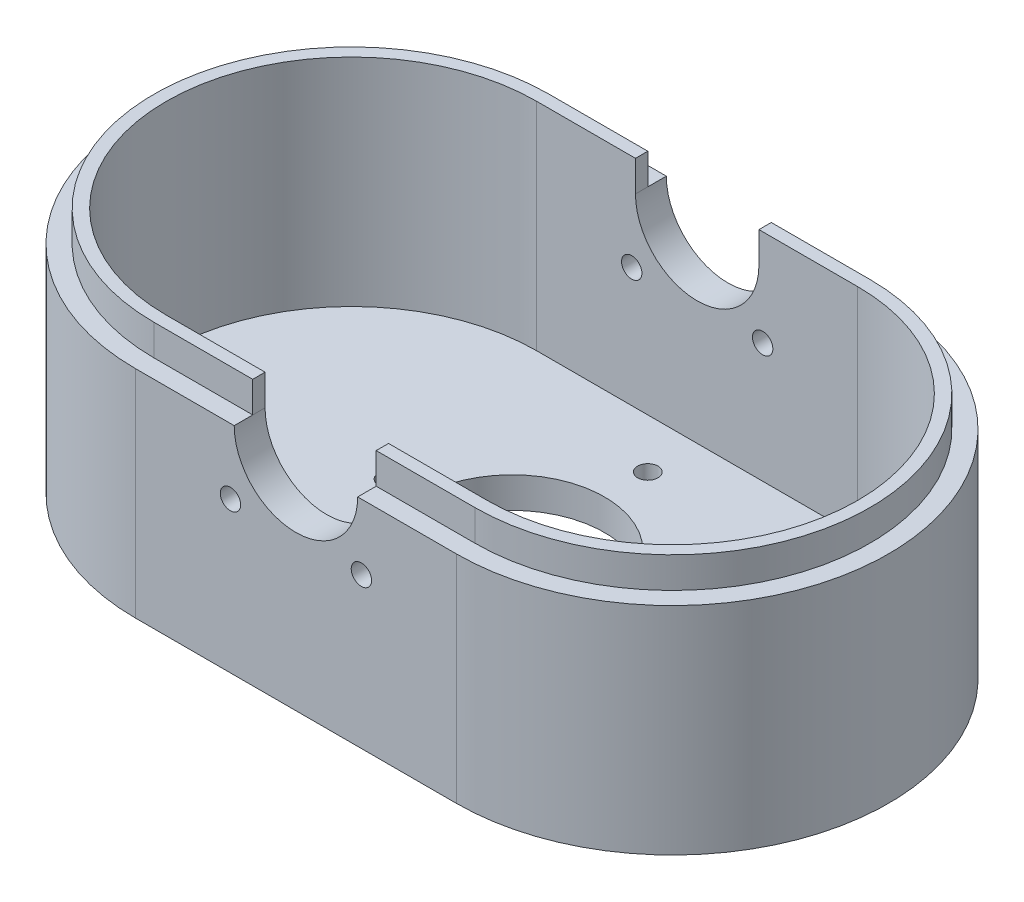
from build123d import *

# Parameters (mm, degrees)
EXTRUDE_1_DEPTH          = 35
CUT_EXTRUDE_1_DEPTH      = 30
SKETCH_3_R               = 10
CUT_EXTRUDE_2_DEPTH      = 1
CUT_EXTRUDE_2_DEPTH_BACK = 71
CUT_EXTRUDE_3_REACH      = 7
SKETCH_4_R               = 15
EXTRUDE_2_DEPTH          = 5
HOLE_WIZARD_M4_1_D       = 3.3
HOLE_WIZARD_M4_1_DEPTH   = 5
HOLE_WIZARD_M4_2_D       = 3.3
HOLE_WIZARD_M4_2_DEPTH   = 5
HOLE_WIZARD_M4_3_D       = 3.3


with BuildPart() as part:
    # 스케치1 → 보스-돌출1 (new body)
    with BuildSketch(Plane(origin=(0, 0, 0), x_dir=(1, 0, 0), z_dir=(0, 1, 0))):
        with BuildLine():
            Line((-26, 35), (26, 35))
            ThreePointArc((26, 35), (61, 0), (26, -35))
            Line((26, -35), (-26, -35))
            ThreePointArc((-26, -35), (-61, 0), (-26, 35))
        make_face()
    extrude(amount=EXTRUDE_1_DEPTH)

    # 스케치2 → 컷-돌출1 (cut)
    with BuildSketch(Plane(origin=(0, 35, 0), x_dir=(1, 0, 0), z_dir=(0, 1, 0))):
        with BuildLine():
            Line((26, 30), (-26, 30))
            ThreePointArc((-26, 30), (-56, 0), (-26, -30))
            Line((-26, -30), (26, -30))
            ThreePointArc((26, -30), (56, 0), (26, 30))
        make_face()
    extrude(amount=-CUT_EXTRUDE_1_DEPTH, mode=Mode.SUBTRACT)

    # 스케치3 → 컷-돌출2 (cut, two sides)
    with BuildSketch(Plane.XY.offset(35)) as cut_extrude_2_sk:
        with Locations((0, 35)):
            Circle(SKETCH_3_R)
    extrude(amount=CUT_EXTRUDE_2_DEPTH, mode=Mode.SUBTRACT)
    extrude(cut_extrude_2_sk.sketch, amount=-CUT_EXTRUDE_2_DEPTH_BACK, mode=Mode.SUBTRACT)

    # 스케치4 → 컷-돌출3 (cut, up to next)
    with BuildSketch(Plane(origin=(0, 5, 0), x_dir=(1, 0, 0), z_dir=(0, 1, 0)), mode=Mode.PRIVATE) as cut_extrude_3_sk1:
        Circle(SKETCH_4_R)
    cut_extrude_3_tool1 = extrude(cut_extrude_3_sk1.sketch, amount=-CUT_EXTRUDE_3_REACH, mode=Mode.PRIVATE) & part.part
    add(cut_extrude_3_tool1.solids().sort_by_distance((0, 5, 0))[0], mode=Mode.SUBTRACT)

    # 스케치5 → 보스-돌출2 (add)
    with BuildSketch(Plane(origin=(0, 35, 0), x_dir=(1, 0, 0), z_dir=(0, 1, 0))):
        with BuildLine():
            Line((-10, 32), (-26, 32))
            ThreePointArc((-26, 32), (-58, 0), (-26, -32))
            Line((-26, -32), (-10, -32))
            Line((-10, -32), (-10, -30))
            Line((-10, -30), (-26, -30))
            ThreePointArc((-26, -30), (-56, 0), (-26, 30))
            Line((-26, 30), (-10, 30))
            Line((-10, 30), (-10, 32))
        make_face()
        with BuildLine():
            Line((10, -32), (26, -32))
            ThreePointArc((26, -32), (58, 0), (26, 32))
            Line((26, 32), (10, 32))
            Line((10, 32), (10, 30))
            Line((10, 30), (26, 30))
            ThreePointArc((26, 30), (56, 0), (26, -30))
            Line((26, -30), (10, -30))
            Line((10, -30), (10, -32))
        make_face()
    extrude(amount=EXTRUDE_2_DEPTH)

    # M4 나사 구멍1
    with Locations(Plane.XY.offset(35)):
        with Locations((-10.606601718, 24.393398282), (10.606601718, 24.393398282)):
            Hole(HOLE_WIZARD_M4_1_D / 2, depth=HOLE_WIZARD_M4_1_DEPTH)

    # M4 나사 구멍2
    with Locations(Plane(origin=(0, 0, -35), x_dir=(-1, 0, 0), z_dir=(0, 0, -1))):
        with Locations((-10.606601718, 24.393398282), (10.606601718, 24.393398282)):
            Hole(HOLE_WIZARD_M4_2_D / 2, depth=HOLE_WIZARD_M4_2_DEPTH)

    # M4 나사 구멍3 (through all)
    with Locations(Plane(origin=(0, 5, 0), x_dir=(1, 0, 0), z_dir=(0, 1, 0))):
        with Locations((0, 22), (-20, 0), (50, 0), (0, -22)):
            Hole(HOLE_WIZARD_M4_3_D / 2)


solid = part.part
